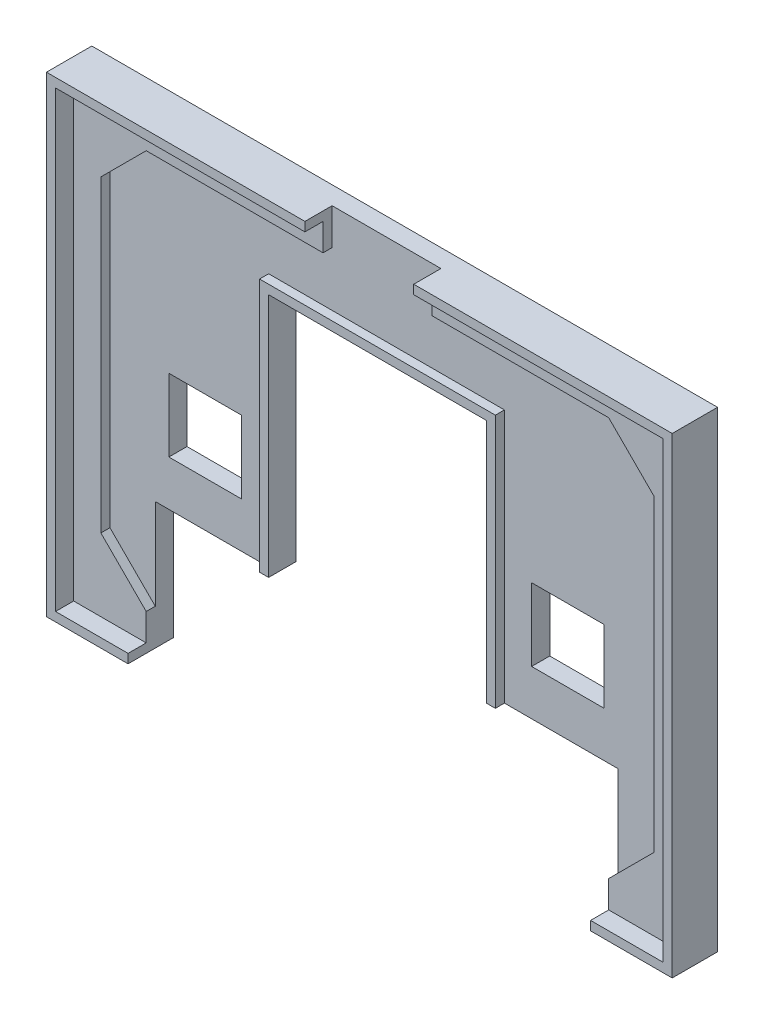
from build123d import *

# Parameters (mm, degrees)
SKICA1_W                    = 67
SKICA1_H                    = 50
P_IDAT_VYSUNUT_M1_DEPTH     = 3
ODEBRAT_VYSUNUT_M1_DEPTH    = 1
SKICA3_W                    = 8
SKICA3_H                    = 8
ODEBRAT_VYSUNUT_M2_DEPTH    = 4
VYSUNOUT_TENKOST_NN_1_DEPTH = 1
VYSUNOUT_TENKOST_NN_2_DEPTH = 5
SKICA6_W                    = 12
SKICA6_H                    = 4
ODEBRAT_VYSUNUT_M3_DEPTH    = 4
SKICA7_W                    = 5
SKICA7_H                    = 5
ODEBRAT_VYSUNUT_M5_DEPTH    = 1
P_IDAT_START                = -1
SKICA8_W                    = 1.6
SKICA8_H                    = 0.8
SKICA8_H_2                  = 2.4
P_IDAT_VYSUNUT_M3_DEPTH     = 1


with BuildPart() as part:
    # Skica1 → Přidat vysunutím1 (new body)
    with BuildSketch(Plane.XY):
        Rectangle(SKICA1_W, SKICA1_H)
    extrude(amount=P_IDAT_VYSUNUT_M1_DEPTH)

    # Skica2 → Odebrat vysunutím1 (cut)
    with BuildSketch(Plane.XY.offset(3)):
        Polygon((-25.5, -22), (-30.5, -17), (-30.5, 17), (-25.5, 22), (25.5, 22), (30.5, 17), (30.5, -17), (25.5, -22), align=None)
    extrude(amount=-ODEBRAT_VYSUNUT_M1_DEPTH, mode=Mode.SUBTRACT)

    # Skica3 → Odebrat vysunutím2 (cut, through all)
    with BuildSketch(Plane(origin=(0, 0, 0), x_dir=(-1, 0, 0), z_dir=(0, 0, -1))):
        with Locations((20, -3)):
            Rectangle(SKICA3_W, SKICA3_H)
        with Locations((-20, -3)):
            Rectangle(SKICA3_W, SKICA3_H)
        Polygon((25.5, -25), (-25.5, -25), (-25.5, -12), (-12, -12), (-12, 15), (12, 15), (12, -12), (25.5, -12), align=None)
    extrude(amount=-ODEBRAT_VYSUNUT_M2_DEPTH, mode=Mode.SUBTRACT)

    # Skica4 → Vysunout tenkostěnný1 (add)
    with BuildSketch(Plane.XY.offset(2)):
        Polygon((-12, -12), (-12, 15), (12, 15), (12, -12), (13, -12), (13, 16), (-13, 16), (-13, -12), align=None)
    extrude(amount=VYSUNOUT_TENKOST_NN_1_DEPTH)

    # Skica5 → Vysunout tenkostěnný2 (add)
    with BuildSketch(Plane(origin=(0, 0, 0), x_dir=(-1, 0, 0), z_dir=(0, 0, -1))):
        Polygon((-25.5, -25), (-33.5, -25), (-33.5, 25), (33.5, 25), (33.5, -25), (25.5, -25), (25.5, -26), (34.5, -26), (34.5, 26), (-34.5, 26), (-34.5, -26), (-25.5, -26), align=None)
    extrude(amount=-VYSUNOUT_TENKOST_NN_2_DEPTH)

    # Skica6 → Odebrat vysunutím3 (cut, through all)
    with BuildSketch(Plane.XY.offset(2)):
        with Locations((0, 24)):
            Rectangle(SKICA6_W, SKICA6_H)
    extrude(amount=ODEBRAT_VYSUNUT_M3_DEPTH, mode=Mode.SUBTRACT)

    # Skica7 → Odebrat vysunutím5 (cut)
    with BuildSketch(Plane(origin=(0, 0, 0), x_dir=(-1, 0, 0), z_dir=(0, 0, -1))):
        with Locations((-28, 18.5)):
            Rectangle(SKICA7_W, SKICA7_H)
        with Locations((-18.5, 18.5)):
            Rectangle(SKICA7_W, SKICA7_H)
        Polygon((-25.5, 15.99), (-25.5, 13.5), (-28, 13.5), (-28, 6), (-25.5, 6), (-25.5, 8.49), (-21, 8.49), (-21, 6), (-18.5, 6), (-18.5, 13.5), (-21, 13.5), (-21, 15.99), align=None)
        Polygon((21, 13.5), (18.5, 13.5), (18.5, 6), (21, 6), (21, 8.49), (25.5, 8.49), (25.5, 6), (28, 6), (28, 13.5), (25.5, 13.5), (25.5, 15.99), (21, 15.99), align=None)
        with Locations((18.5, 18.5)):
            Rectangle(SKICA7_W, SKICA7_H)
        with Locations((28, 18.5)):
            Rectangle(SKICA7_W, SKICA7_H)
        Polygon((-11.2, 23.3), (-11.2, 17.7), (-7.2, 17.7), (-7.2, 18.5), (-6.4, 18.5), (-6.4, 20.1), (-7.2, 20.1), (-7.2, 20.9), (-6.4, 20.9), (-6.4, 22.5), (-7.2, 22.5), (-7.2, 23.3), align=None)
        Polygon((-1.6, 23.3), (-4.8, 23.3), (-4.8, 22.5), (-5.6, 22.5), (-5.6, 18.5), (-4.8, 18.5), (-4.8, 17.7), (-1.6, 17.7), (-1.6, 18.5), (-0.8, 18.5), (-0.8, 22.5), (-1.6, 22.5), align=None)
        Polygon((0.8, 23.3), (0.8, 22.5), (0, 22.5), (0, 18.5), (0.8, 18.5), (0.8, 17.7), (4, 17.7), (4, 18.5), (4.8, 18.5), (4.8, 22.5), (4, 22.5), (4, 23.3), align=None)
        Polygon((5.6, 17.7), (5.6, 23.3), (7.2, 23.3), (7.2, 22.5), (8, 22.5), (8, 21.7), (8.8, 21.7), (8.8, 22.5), (9.6, 22.5), (9.6, 23.3), (11.2, 23.3), (11.2, 17.7), (9.6, 17.7), (9.6, 19.3), (8.8, 19.3), (8.8, 18.5), (8, 18.5), (8, 19.3), (7.2, 19.3), (7.2, 17.7), align=None)
    extrude(amount=-ODEBRAT_VYSUNUT_M5_DEPTH, mode=Mode.SUBTRACT)

    # Skica8 → Přidat vysunutím3 (add)
    with BuildSketch(Plane(origin=(0, 0, 0), x_dir=(-1, 0, 0), z_dir=(0, 0, -1)).offset(P_IDAT_START)):
        with Locations((-8.8, 21.3)):
            Rectangle(SKICA8_W, SKICA8_H)
        with Locations((-8.8, 19.7)):
            Rectangle(SKICA8_W, SKICA8_H)
        with Locations((-3.2, 20.5)):
            Rectangle(SKICA8_W, SKICA8_H_2)
        with Locations((2.4, 20.5)):
            Rectangle(SKICA8_W, SKICA8_H_2)
    extrude(amount=P_IDAT_VYSUNUT_M3_DEPTH)


solid = part.part
